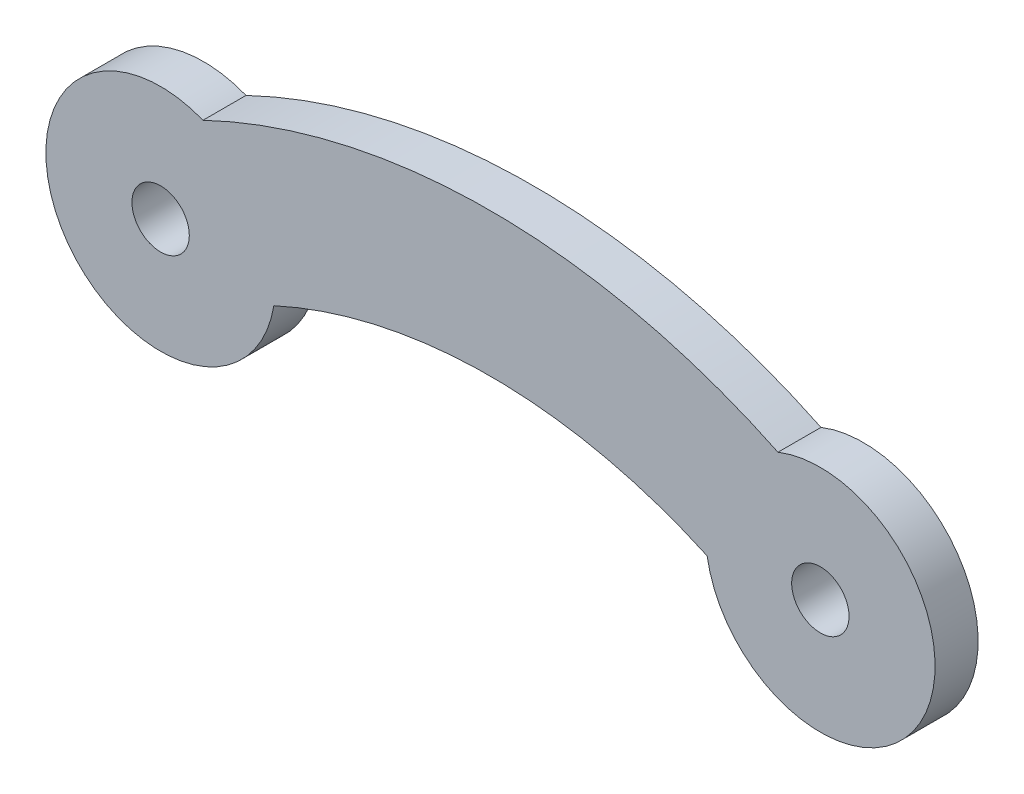
from build123d import *

# Parameters (mm, degrees)
SKETCH1_R           = 1
BOSS_EXTRUDE1_DEPTH = 1.5


with BuildPart() as part:
    # Sketch1 → Boss-Extrude1 (new body)
    with BuildSketch(Plane.XY):
        with BuildLine():
            ThreePointArc((1.477428659, 3.717150059), (-3.481097701, -1.970268712), (3.947365166, -0.646767534))
            ThreePointArc((3.947365166, -0.646767534), (11.5, 1), (19.052634834, -0.646767534))
            ThreePointArc((19.052634834, -0.646767534), (26.481097701, -1.970268712), (21.522571341, 3.717150059))
            ThreePointArc((21.522571341, 3.717150059), (11.5, 6), (1.477428659, 3.717150059))
        make_face()
        Circle(SKETCH1_R, mode=Mode.SUBTRACT)
        with Locations((23, 0)):
            Circle(SKETCH1_R, mode=Mode.SUBTRACT)
    extrude(amount=BOSS_EXTRUDE1_DEPTH)


solid = part.part
